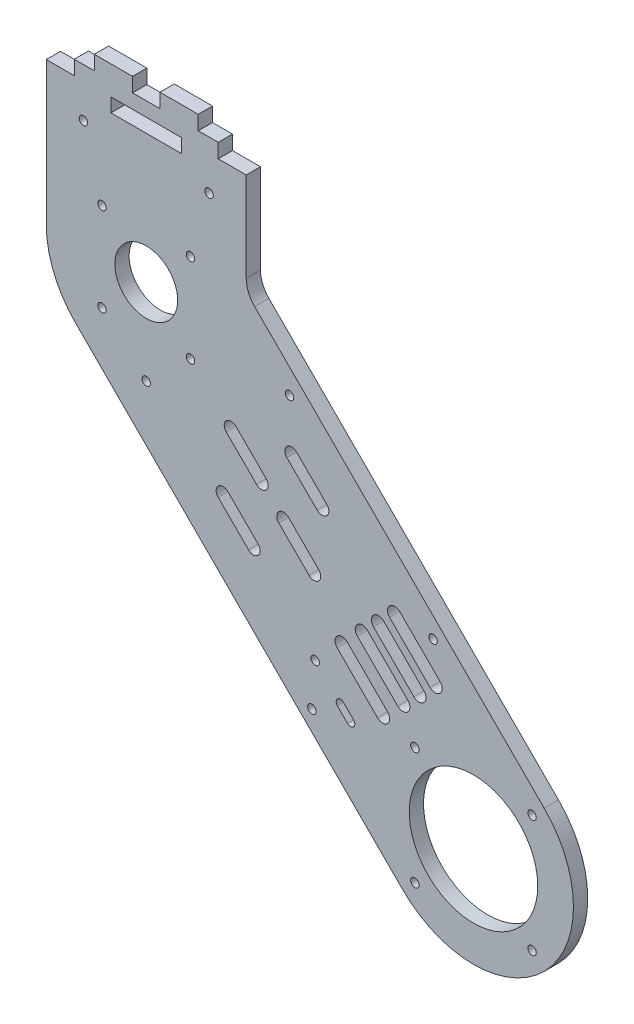
from build123d import *

# Parameters (mm, degrees)
SKETCH1_R           = 1.475
SKETCH1_R_2         = 22.5
SKETCH1_R_3         = 11
SKETCH1_W           = 24.7
SKETCH1_H           = 4.85
BOSS_EXTRUDE1_DEPTH = 5


with BuildPart() as part:
    # Sketch1 → Boss-Extrude1 (new body)
    with BuildSketch(Plane.XY):
        with BuildLine():
            Line((-139.300035894, 89.802561211), (-24.748737342, -24.748737342))
            ThreePointArc((-24.748737342, -24.748737342), (24.748737342, -24.748737342), (24.748737342, 24.748737342))
            Line((24.748737342, 24.748737342), (-54.672802234, 104.170276917))
            Line((-54.672802234, 104.170276917), (-76.622366364, 126.119841047))
            ThreePointArc((-76.622366364, 126.119841047), (-78.790093877, 129.364074535), (-79.551298552, 133.190908859))
            Line((-79.551298552, 133.190908859), (-79.551298552, 164.551298552))
            Line((-79.551298552, 164.551298552), (-89.351298552, 164.551298552))
            Line((-89.351298552, 164.551298552), (-89.351298552, 169.551298552))
            Line((-89.351298552, 169.551298552), (-96.351298552, 169.551298552))
            Line((-96.351298552, 169.551298552), (-96.351298552, 174.551298552))
            Line((-96.351298552, 174.551298552), (-109.751298552, 174.551298552))
            Line((-109.751298552, 174.551298552), (-109.751298552, 169.551298552))
            Line((-109.751298552, 169.551298552), (-119.351298552, 169.551298552))
            Line((-119.351298552, 169.551298552), (-119.351298552, 174.551298552))
            Line((-119.351298552, 174.551298552), (-132.751298552, 174.551298552))
            Line((-132.751298552, 174.551298552), (-132.751298552, 169.551298552))
            Line((-132.751298552, 169.551298552), (-139.751298552, 169.551298552))
            Line((-139.751298552, 169.551298552), (-139.751298552, 164.551298552))
            Line((-139.751298552, 164.551298552), (-149.551298552, 164.551298552))
            Line((-149.551298552, 164.551298552), (-149.551298552, 114.551298552))
            ThreePointArc((-149.551298552, 114.551298552), (-146.88708219, 101.157378419), (-139.300035894, 89.802561211))
        make_face()
        with BuildLine():
            Line((-78.771695424, 51.335952314), (-89.378297142, 61.942554032))
            ThreePointArc((-89.378297142, 61.942554032), (-89.378297142, 65.336666582), (-85.984184592, 65.336666582))
            Line((-85.984184592, 65.336666582), (-75.377582874, 54.730064864))
            ThreePointArc((-75.377582874, 54.730064864), (-75.377582874, 51.335952314), (-78.771695424, 51.335952314))
        make_face(mode=Mode.SUBTRACT)
        with BuildLine():
            ThreePointArc((-68.165093707, 64.770981156), (-68.165093707, 68.165093706), (-64.770981157, 68.165093706))
            Line((-64.770981157, 68.165093706), (-54.164379439, 57.558491989))
            ThreePointArc((-54.164379439, 57.558491989), (-54.164379439, 54.164379439), (-57.558491988, 54.164379439))
            Line((-57.558491988, 54.164379439), (-68.165093707, 64.770981156))
        make_face(mode=Mode.SUBTRACT)
        with Locations((-20.506096654, -20.506096654)):
            Circle(SKETCH1_R, mode=Mode.SUBTRACT)
        with Locations((-56.568542495, 14.142135624)):
            Circle(SKETCH1_R, mode=Mode.SUBTRACT)
        with Locations((20.506096654, -20.506096654)):
            Circle(SKETCH1_R, mode=Mode.SUBTRACT)
        Circle(SKETCH1_R_2, mode=Mode.SUBTRACT)
        with Locations((-55.401816306, 29.450997436)):
            Circle(SKETCH1_R, mode=Mode.SUBTRACT)
        with BuildLine():
            ThreePointArc((-47.623641713, 19.5515025), (-47.623641713, 21.672822843), (-45.502321369, 21.672822843))
            Line((-45.502321369, 21.672822843), (-41.966787463, 18.137288937))
            ThreePointArc((-41.966787463, 18.137288937), (-41.966787463, 16.015968594), (-44.088107807, 16.015968594))
            Line((-44.088107807, 16.015968594), (-47.623641713, 19.5515025))
        make_face(mode=Mode.SUBTRACT)
        with BuildLine():
            ThreePointArc((-47.72970773, 37.123106012), (-47.72970773, 40.658639918), (-44.194173824, 40.658639918))
            Line((-44.194173824, 40.658639918), (-30.0520382, 26.516504294))
            ThreePointArc((-30.0520382, 26.516504294), (-30.0520382, 22.980970389), (-33.587572106, 22.980970389))
            Line((-33.587572106, 22.980970389), (-47.72970773, 37.123106012))
        make_face(mode=Mode.SUBTRACT)
        with Locations((-20.506096654, 20.506096654)):
            Circle(SKETCH1_R, mode=Mode.SUBTRACT)
        with BuildLine():
            ThreePointArc((-40.658639918, 44.194173824), (-40.658639918, 47.72970773), (-37.123106012, 47.72970773))
            Line((-37.123106012, 47.72970773), (-22.980970389, 33.587572106))
            ThreePointArc((-22.980970389, 33.587572106), (-22.980970389, 30.0520382), (-26.516504294, 30.0520382))
            Line((-26.516504294, 30.0520382), (-40.658639918, 44.194173824))
        make_face(mode=Mode.SUBTRACT)
        with BuildLine():
            ThreePointArc((-35.001785669, 49.851028074), (-35.001785669, 53.38656198), (-31.466251763, 53.38656198))
            Line((-31.466251763, 53.38656198), (-17.324116139, 39.244426356))
            ThreePointArc((-17.324116139, 39.244426356), (-17.324116139, 35.70889245), (-20.859650045, 35.70889245))
            Line((-20.859650045, 35.70889245), (-35.001785669, 49.851028074))
        make_face(mode=Mode.SUBTRACT)
        with BuildLine():
            ThreePointArc((-29.344931419, 55.507882323), (-29.344931419, 59.043416229), (-25.809397513, 59.043416229))
            Line((-25.809397513, 59.043416229), (-11.66726189, 44.901280605))
            ThreePointArc((-11.66726189, 44.901280605), (-11.66726189, 41.365746699), (-15.202795796, 41.365746699))
            Line((-15.202795796, 41.365746699), (-29.344931419, 55.507882323))
        make_face(mode=Mode.SUBTRACT)
        with Locations((-14.142135624, 56.568542495)):
            Circle(SKETCH1_R, mode=Mode.SUBTRACT)
        with Locations((20.506096654, 20.506096654)):
            Circle(SKETCH1_R, mode=Mode.SUBTRACT)
        with Locations((-114.551298552, 84.551298552)):
            Circle(SKETCH1_R, mode=Mode.SUBTRACT)
        with Locations((-130.051298552, 99.051298552)):
            Circle(SKETCH1_R, mode=Mode.SUBTRACT)
        with Locations((-114.551298552, 114.551298552)):
            Circle(SKETCH1_R_3, mode=Mode.SUBTRACT)
        with BuildLine():
            ThreePointArc((-86.549870017, 83.155757468), (-86.549870017, 86.549870017), (-83.155757468, 86.549870017))
            Line((-83.155757468, 86.549870017), (-72.54915575, 75.943268299))
            ThreePointArc((-72.54915575, 75.943268299), (-72.54915575, 72.54915575), (-75.943268299, 72.54915575))
            Line((-75.943268299, 72.54915575), (-86.549870017, 83.155757468))
        make_face(mode=Mode.SUBTRACT)
        with BuildLine():
            ThreePointArc((-65.336666582, 85.984184592), (-65.336666582, 89.378297142), (-61.942554032, 89.378297142))
            Line((-61.942554032, 89.378297142), (-51.335952314, 78.771695424))
            ThreePointArc((-51.335952314, 78.771695424), (-51.335952314, 75.377582874), (-54.730064864, 75.377582874))
            Line((-54.730064864, 75.377582874), (-65.336666582, 85.984184592))
        make_face(mode=Mode.SUBTRACT)
        with Locations((-99.051298552, 99.051298552)):
            Circle(SKETCH1_R, mode=Mode.SUBTRACT)
        with Locations((-64.396887007, 105.308740477)):
            Circle(SKETCH1_R, mode=Mode.SUBTRACT)
        with Locations((-130.051298552, 130.051298552)):
            Circle(SKETCH1_R, mode=Mode.SUBTRACT)
        with Locations((-136.551298552, 152.551298552)):
            Circle(SKETCH1_R, mode=Mode.SUBTRACT)
        with Locations((-114.551298552, 162.126298552)):
            Rectangle(SKETCH1_W, SKETCH1_H, mode=Mode.SUBTRACT)
        with Locations((-99.051298552, 130.051298552)):
            Circle(SKETCH1_R, mode=Mode.SUBTRACT)
        with Locations((-92.551298552, 152.551298552)):
            Circle(SKETCH1_R, mode=Mode.SUBTRACT)
    extrude(amount=-BOSS_EXTRUDE1_DEPTH)


solid = part.part
